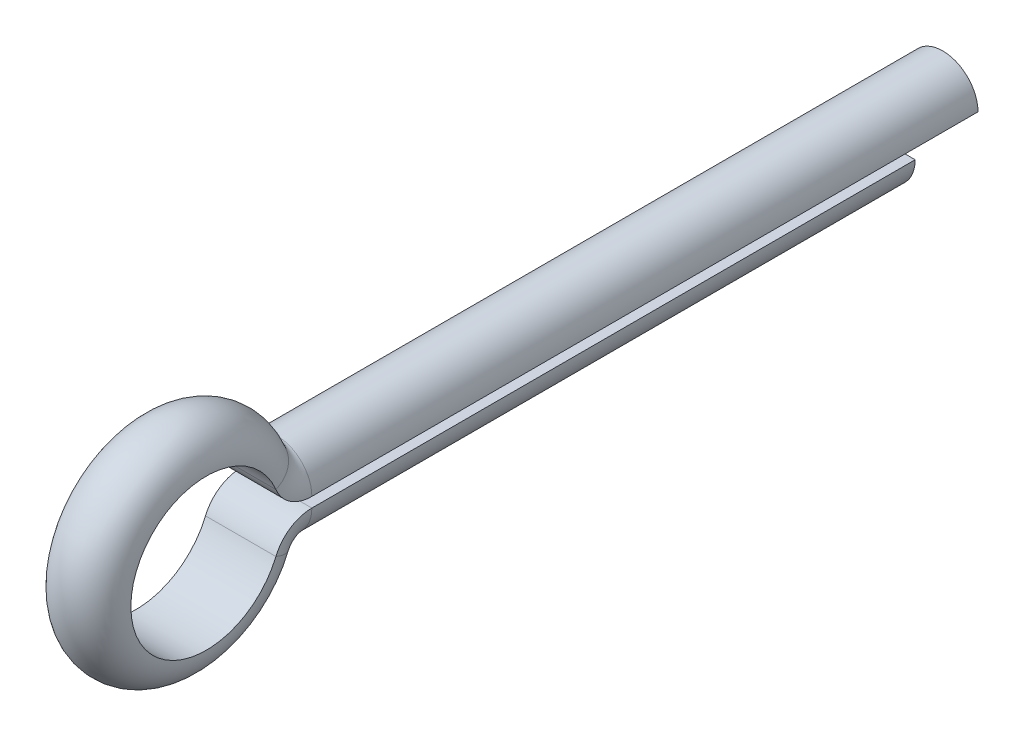
from build123d import *

# Parameters (mm, degrees)
DODANIE_WYCI_GNI_CIE1_DEPTH = 1.25


with BuildPart() as part:
    # Wyciągnięcie po ścieżce1: sweep along a path in Szkic1
    with BuildLine(Plane(origin=(0, 0, 0), x_dir=(0, 0, -1), z_dir=(1, 0, 0))) as wyci_gni_cie_po_cie_ce1_path:
        Line((0, 0), (-12, 0))
        ThreePointArc((-12, 0), (-12.485362672, -0.146955992), (-12.807692308, -0.538461538))
        ThreePointArc((-12.807692308, -0.538461538), (-14.374562589, -1.372812946), (-15.5, 0))
    # Szkic2 → Wyciągnięcie po ścieżce1 (sweep)
    with BuildSketch(Plane.XY):
        with BuildLine():
            Line((-0.7, -0.1), (0.7, -0.1))
            ThreePointArc((0.7, -0.1), (0, -0.8), (-0.7, -0.1))
        make_face()
    wyci_gni_cie_po_cie_ce1 = sweep(path=wyci_gni_cie_po_cie_ce1_path.line)

    # Lustro1: Wyciągnięcie po ścieżce1 across plane
    add(wyci_gni_cie_po_cie_ce1.mirror(Plane.ZX))

    # Szkic3 → Dodanie-wyciągnięcie1 (add)
    with BuildSketch(Plane(origin=(0, 0, 0), x_dir=(-1, 0, 0), z_dir=(0, 0, -1))):
        with BuildLine():
            Line((0.7, 0.1), (-0.7, 0.1))
            ThreePointArc((-0.7, 0.1), (0, 0.8), (0.7, 0.1))
        make_face()
    extrude(amount=DODANIE_WYCI_GNI_CIE1_DEPTH)


solid = part.part
